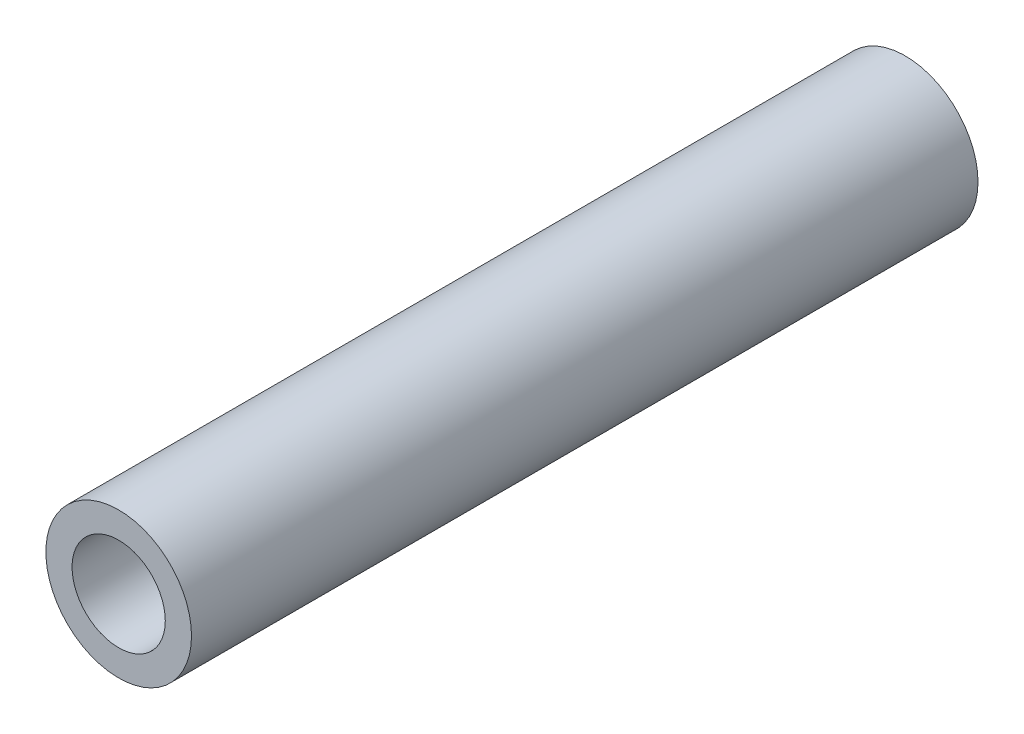
from build123d import *

# Parameters (mm, degrees)
SKETCH1_R           = 2.5
SKETCH1_R_2         = 1.6
BOSS_EXTRUDE3_DEPTH = 27


with BuildPart() as part:
    # Sketch1 → Boss-Extrude3 (new body)
    with BuildSketch(Plane.XY):
        Circle(SKETCH1_R)
        Circle(SKETCH1_R_2, mode=Mode.SUBTRACT)
    extrude(amount=BOSS_EXTRUDE3_DEPTH)


solid = part.part
